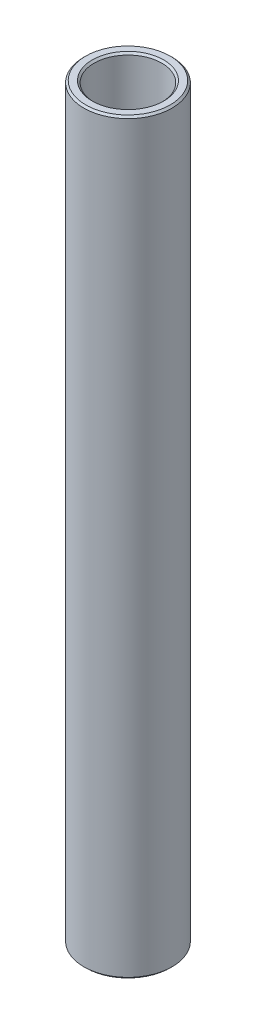
from build123d import *

# Parameters (mm, degrees)
SKETCH1_W     = 0.7
SKETCH1_H     = 50.8
CHAMFER1_SIZE = 0.127


with BuildPart() as part:
    # Sketch1 → Revolve1 (revolve)
    with BuildSketch(Plane.XY):
        with Locations((2.65, 0)):
            Rectangle(SKETCH1_W, SKETCH1_H)
    revolve(axis=Axis((0, 19.067988669, 0), (0, -1, 0)))

    # Chamfer1
    chamfer1_edges = [part.edges().sort_by_distance(p)[0] for p in [
        (-3, 25.4, 0),
        (-3, -25.4, 0),
        (-2.3, -25.4, 0),
        (-2.3, 25.4, 0),
    ]]
    chamfer(chamfer1_edges, length=CHAMFER1_SIZE)


solid = part.part
